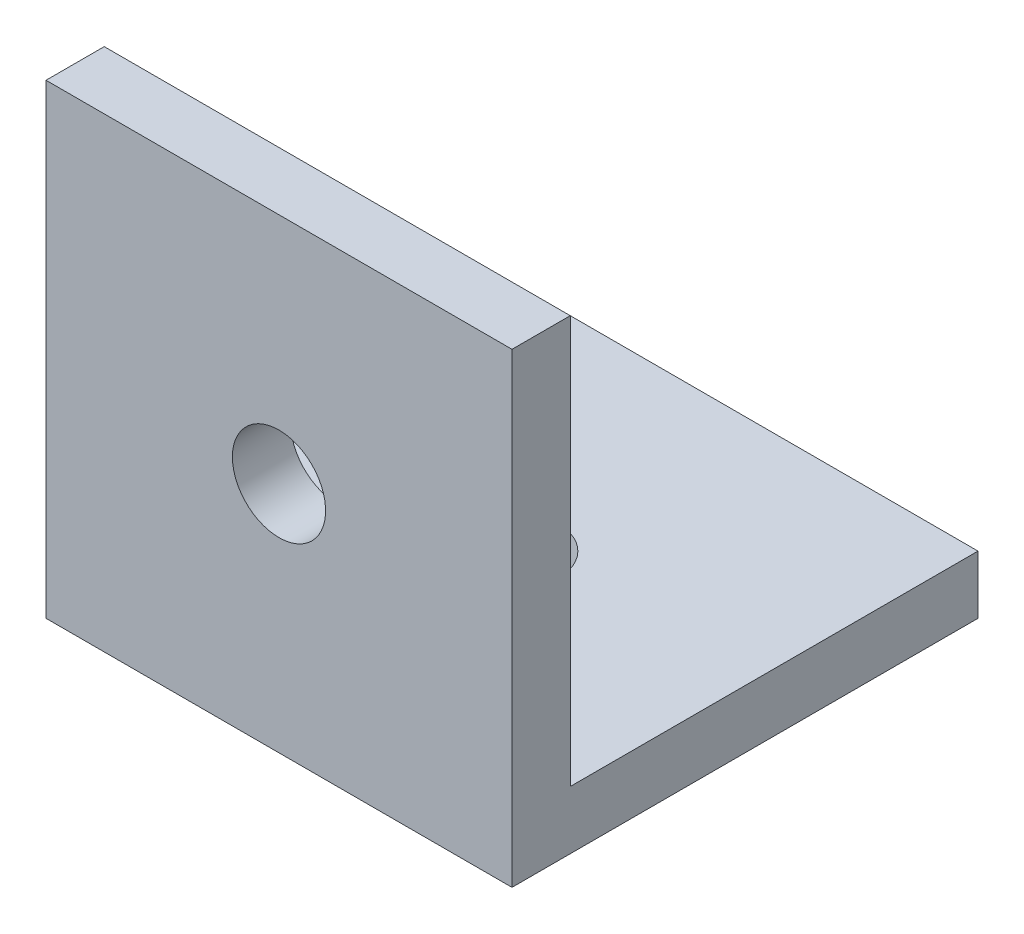
from build123d import *

# Parameters (mm, degrees)
SKETCH4_W           = 25.4
SKETCH4_H           = 25.4
BOSS_EXTRUDE3_DEPTH = 3.175
SKETCH5_W           = 25.4
SKETCH5_H           = 3.175
BOSS_EXTRUDE4_DEPTH = 22.225
SKETCH6_R           = 2.54
CUT_EXTRUDE1_DEPTH  = 4.175
SKETCH7_R           = 2.54
CUT_EXTRUDE2_DEPTH  = 4.175


with BuildPart() as part:
    # Sketch4 → Boss-Extrude3 (new body)
    with BuildSketch(Plane.XY):
        Rectangle(SKETCH4_W, SKETCH4_H)
    extrude(amount=BOSS_EXTRUDE3_DEPTH)

    # Sketch5 → Boss-Extrude4 (add)
    with BuildSketch(Plane(origin=(0, 0, 0), x_dir=(-1, 0, 0), z_dir=(0, 0, -1))):
        with Locations((0, -11.1125)):
            Rectangle(SKETCH5_W, SKETCH5_H)
    extrude(amount=BOSS_EXTRUDE4_DEPTH)

    # Sketch6 → Cut-Extrude1 (cut, through all)
    with BuildSketch(Plane(origin=(0, -9.525, 0), x_dir=(1, 0, 0), z_dir=(0, 1, 0))):
        with Locations((0, 9.525)):
            Circle(SKETCH6_R)
    extrude(amount=-CUT_EXTRUDE1_DEPTH, mode=Mode.SUBTRACT)

    # Sketch7 → Cut-Extrude2 (cut, through all)
    with BuildSketch(Plane(origin=(0, 0, 0), x_dir=(-1, 0, 0), z_dir=(0, 0, -1))):
        Circle(SKETCH7_R)
    extrude(amount=-CUT_EXTRUDE2_DEPTH, mode=Mode.SUBTRACT)


solid = part.part
